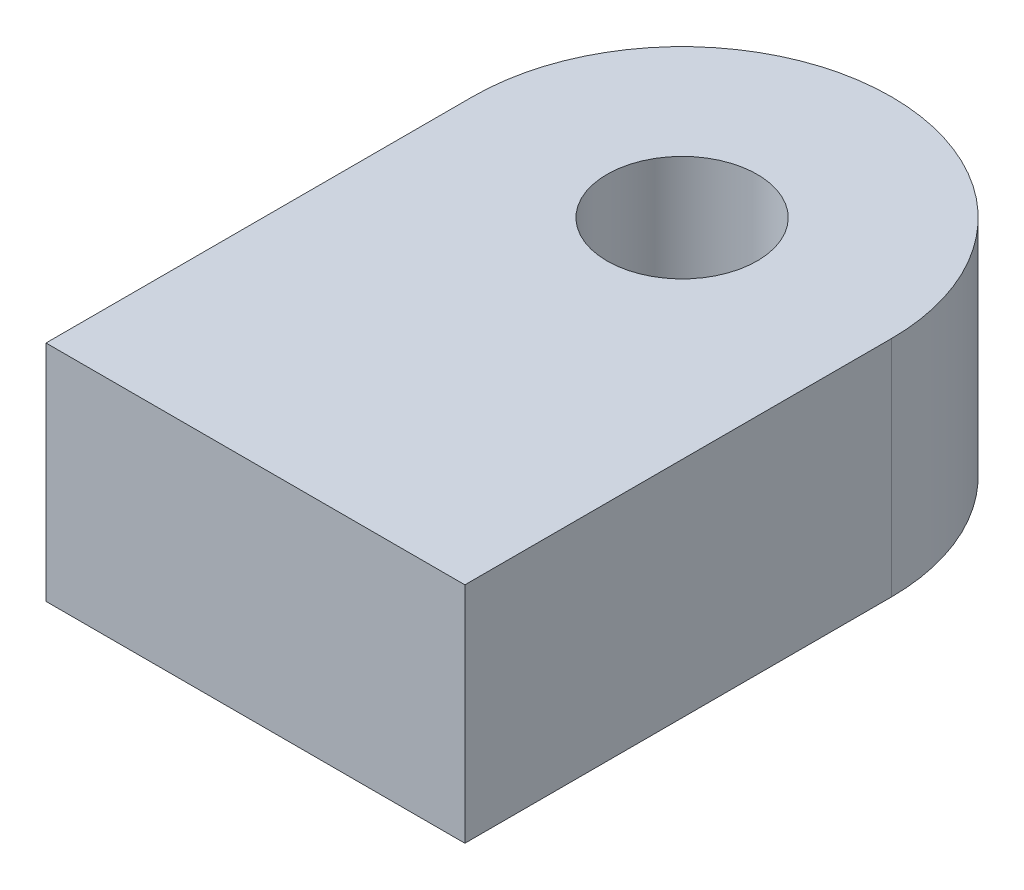
from build123d import *

# Parameters (mm, degrees)
SKETCH1_R           = 5.565
BOSS_EXTRUDE1_DEPTH = 16.59


with BuildPart() as part:
    # Sketch1 → Boss-Extrude1 (new body)
    with BuildSketch(Plane(origin=(0, 0, 0), x_dir=(1, 0, 0), z_dir=(0, 1, 0))):
        with BuildLine():
            Line((0, 0), (31.05, 0))
            Line((31.05, 0), (31.05, 31.62))
            ThreePointArc((31.05, 31.62), (26.504297244, 42.594297244), (15.53, 47.14))
            Line((15.53, 47.14), (15.52, 47.14))
            ThreePointArc((15.52, 47.14), (4.545702756, 42.594297244), (0, 31.62))
            Line((0, 31.62), (0, 0))
        make_face()
        with Locations((15.53, 31.62)):
            Circle(SKETCH1_R, mode=Mode.SUBTRACT)
    extrude(amount=BOSS_EXTRUDE1_DEPTH)


solid = part.part
